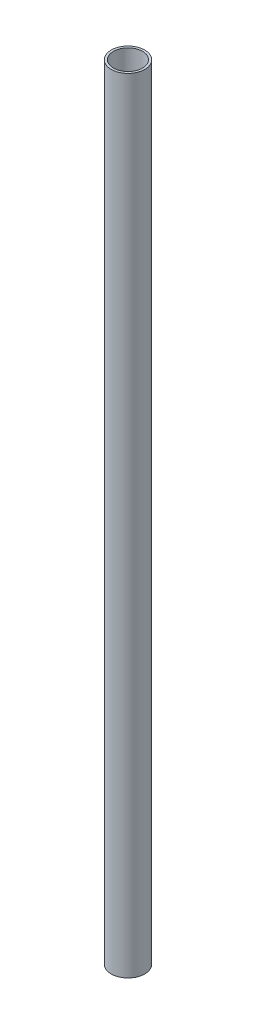
from build123d import *

# Parameters (mm, degrees)
SKETCH1_R           = 15
SKETCH1_R_2         = 13
BOSS_EXTRUDE1_DEPTH = 700


with BuildPart() as part:
    # Sketch1 → Boss-Extrude1 (new body)
    with BuildSketch(Plane(origin=(0, 0, 0), x_dir=(1, 0, 0), z_dir=(0, 1, 0))):
        Circle(SKETCH1_R)
        Circle(SKETCH1_R_2, mode=Mode.SUBTRACT)
    extrude(amount=BOSS_EXTRUDE1_DEPTH)


solid = part.part
